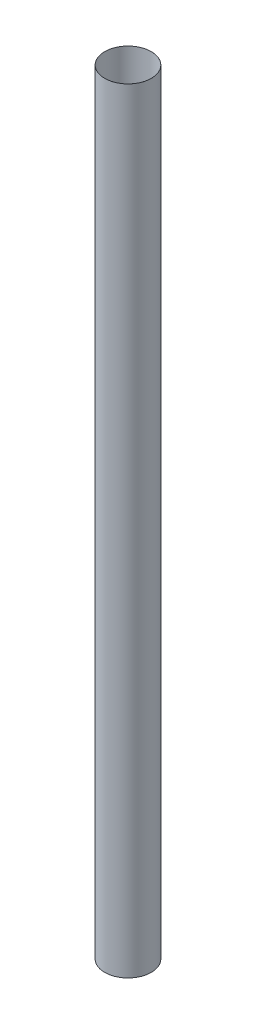
from build123d import *

# Parameters (mm, degrees)
SKETCH1_R           = 38.1254
SKETCH1_R_2         = 38.1
BOSS_EXTRUDE1_DEPTH = 1270


with BuildPart() as part:
    # Sketch1 → Boss-Extrude1 (new body)
    with BuildSketch(Plane(origin=(0, 0, 0), x_dir=(1, 0, 0), z_dir=(0, 1, 0))):
        Circle(SKETCH1_R)
        Circle(SKETCH1_R_2, mode=Mode.SUBTRACT)
    extrude(amount=BOSS_EXTRUDE1_DEPTH)


solid = part.part
